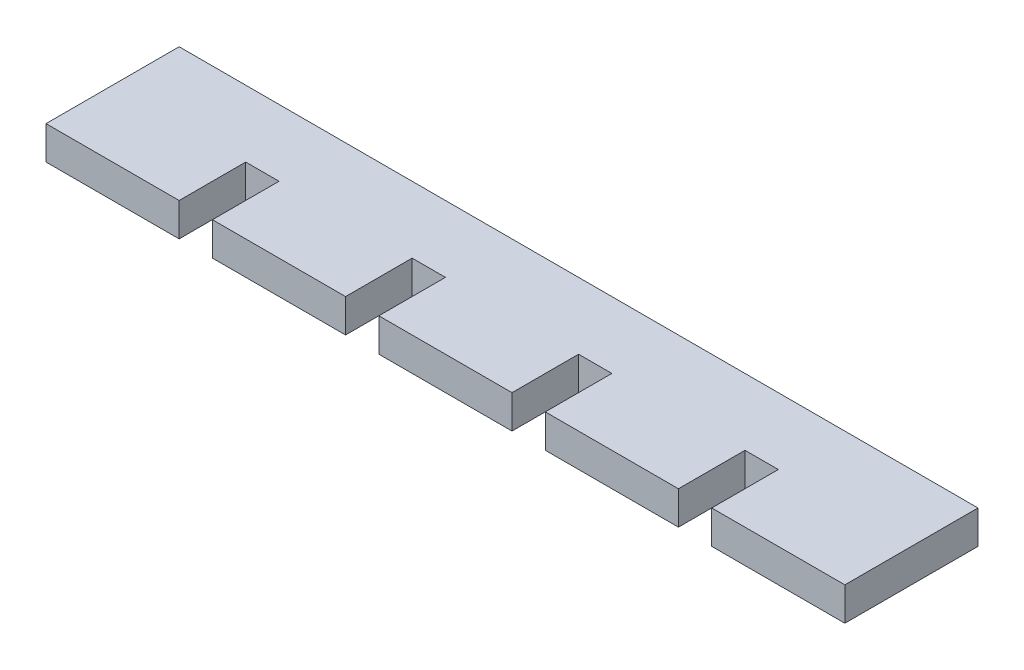
from build123d import *

# Parameters (mm, degrees)
SKETCH1_W           = 76.2
SKETCH1_H           = 12.7
BOSS_EXTRUDE1_DEPTH = 3.175
SKETCH4_W           = 3.175
SKETCH4_H           = 6.35
CUT_EXTRUDE1_DEPTH  = 4.175
LPATTERN1_COUNT     = 4
LPATTERN1_PITCH     = 15.875


with BuildPart() as part:
    # Sketch1 → Boss-Extrude1 (new body)
    with BuildSketch(Plane(origin=(0, 0, 0), x_dir=(1, 0, 0), z_dir=(0, 1, 0))):
        with Locations((38.1, -6.35)):
            Rectangle(SKETCH1_W, SKETCH1_H)
    extrude(amount=BOSS_EXTRUDE1_DEPTH)

    # Sketch4 → Cut-Extrude1 (cut, through all)
    with BuildSketch(Plane(origin=(0, 3.175, 0), x_dir=(1, 0, 0), z_dir=(0, 1, 0))):
        with Locations((14.2875, -9.525)):
            Rectangle(SKETCH4_W, SKETCH4_H)
    cut_extrude1 = extrude(amount=-CUT_EXTRUDE1_DEPTH, mode=Mode.SUBTRACT)

    # LPattern1: Cut-Extrude1 ×4
    with Locations(*[(i * LPATTERN1_PITCH, 0, 0) for i in range(1, LPATTERN1_COUNT)]):
        add(cut_extrude1, mode=Mode.SUBTRACT)


solid = part.part
